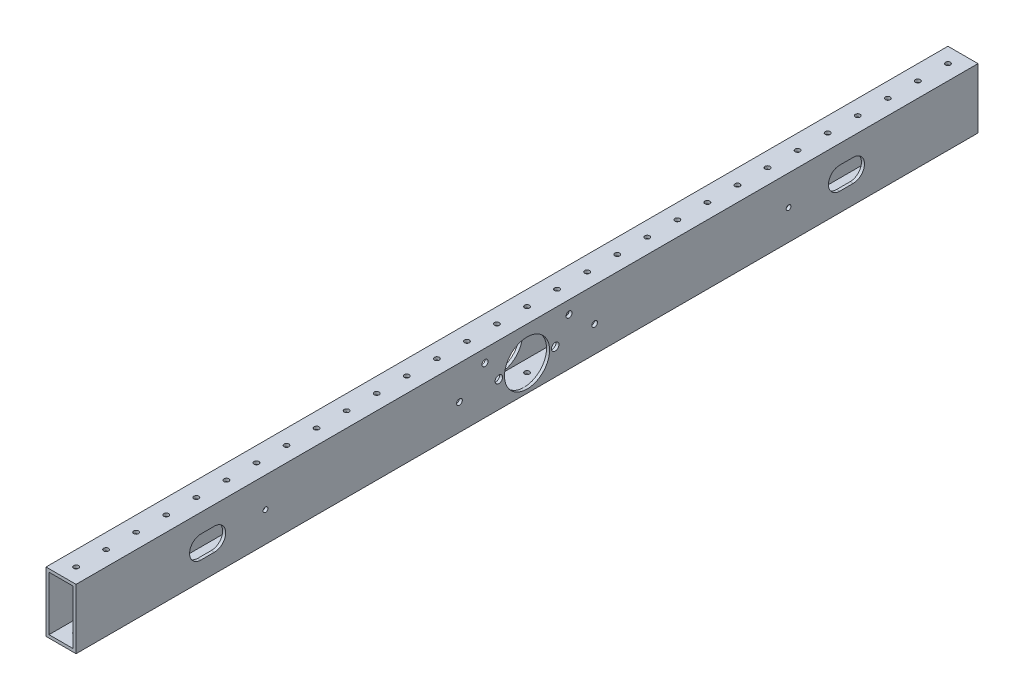
from build123d import *

# Parameters (mm, degrees)
SKETCH1_W           = 25.4
SKETCH1_H           = 50.8
SKETCH1_W_2         = 20.32
SKETCH1_H_2         = 45.72
EXTRUDE_THIN1_DEPTH = 381
SKETCH2_R           = 2.0701
CUT_EXTRUDE1_DEPTH  = 385.581499815
LPATTERN1_COUNT     = 31
LPATTERN1_PITCH     = 25.4
SKETCH3_R           = 19.05
SKETCH3_R_2         = 3.175
SKETCH3_R_3         = 2.413
SKETCH3_R_4         = 2.54
CUT_EXTRUDE2_DEPTH  = 383.689587002
SKETCH3_3_R         = 2.0193
CUT_EXTRUDE3_DEPTH  = 383.689587002


with BuildPart() as part:
    # Sketch1 → Extrude-Thin1 (new, symmetric)
    with BuildSketch(Plane.XY):
        Rectangle(SKETCH1_W, SKETCH1_H)
        Rectangle(SKETCH1_W_2, SKETCH1_H_2, mode=Mode.SUBTRACT)
    extrude(amount=EXTRUDE_THIN1_DEPTH, both=True)

    # Sketch2 → Cut-Extrude1 (cut, through all)
    with BuildSketch(Plane(origin=(0, 25.4, 0), x_dir=(1, 0, 0), z_dir=(0, 1, 0))):
        with Locations((0, -368.3)):
            Circle(SKETCH2_R)
    cut_extrude1 = extrude(amount=-CUT_EXTRUDE1_DEPTH, mode=Mode.SUBTRACT)

    # LPattern1: Cut-Extrude1 ×31
    with Locations(*[(0, 0, -i * LPATTERN1_PITCH) for i in range(1, LPATTERN1_COUNT)]):
        add(cut_extrude1, mode=Mode.SUBTRACT)

    # Sketch3 → Cut-Extrude2 (cut, through all)
    with BuildSketch(Plane(origin=(12.7, 0, 0), x_dir=(0, 0, -1), z_dir=(1, 0, 0))):
        with Locations((0, -3.175)):
            Circle(SKETCH3_R)
        with Locations((-23.8125, -3.175)):
            Circle(SKETCH3_R_2)
        with Locations((23.8125, -3.175)):
            Circle(SKETCH3_R_2)
        with Locations((-57.0865, -3.175)):
            Circle(SKETCH3_R_3)
        with Locations((57.0865, -3.175)):
            Circle(SKETCH3_R_3)
        with Locations((-35.4965, 14.605)):
            Circle(SKETCH3_R_4)
        with Locations((35.4965, 14.605)):
            Circle(SKETCH3_R_4)
    extrude(amount=-CUT_EXTRUDE2_DEPTH, mode=Mode.SUBTRACT)

    # Sketch3_3 → Cut-Extrude3 (cut, through all)
    with BuildSketch(Plane(origin=(12.7, 0, 0), x_dir=(0, 0, -1), z_dir=(1, 0, 0))):
        with BuildLine():
            Line((-264.141100521, 9.525), (-275.571100521, 9.525))
            ThreePointArc((-275.571100521, 9.525), (-285.096100521, 0), (-275.571100521, -9.525))
            Line((-275.571100521, -9.525), (-264.141100521, -9.525))
            ThreePointArc((-264.141100521, -9.525), (-254.616100521, 0), (-264.141100521, 9.525))
        make_face()
        with Locations((-220.961100521, 0)):
            Circle(SKETCH3_3_R)
    cut_extrude3 = extrude(amount=-CUT_EXTRUDE3_DEPTH, mode=Mode.SUBTRACT)

    # Mirror1: Cut-Extrude3 across plane
    add(cut_extrude3.mirror(Plane.XY), mode=Mode.SUBTRACT)


solid = part.part
